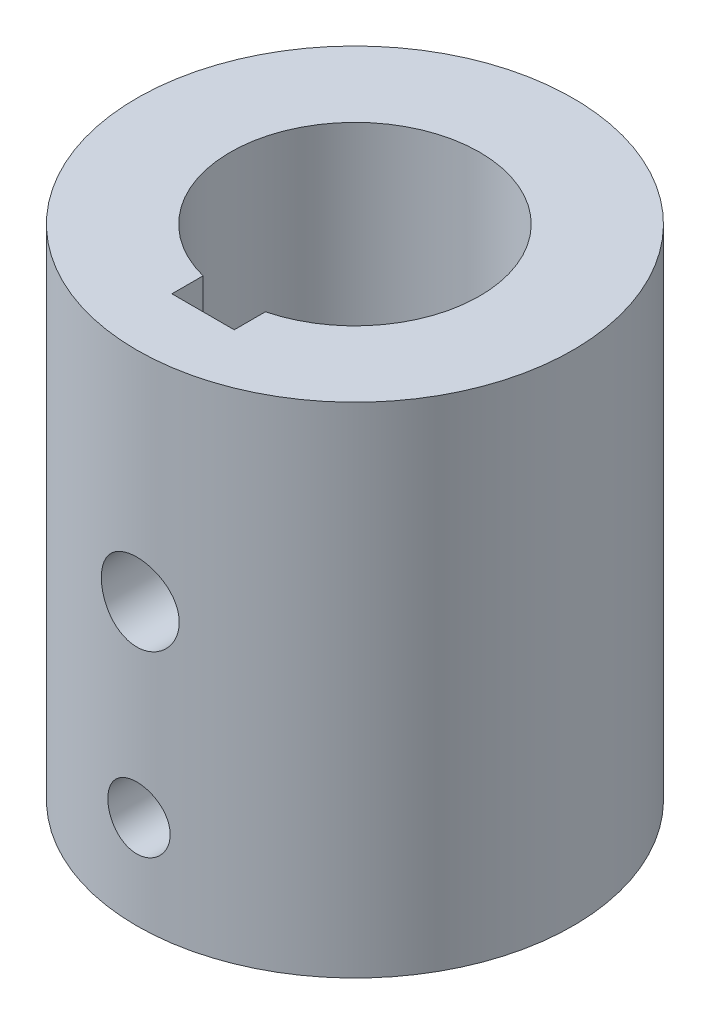
from build123d import *

# Parameters (mm, degrees)
SKETCH1_R                           = 22.225
SKETCH1_R_2                         = 12.7
BOSS_EXTRUDE1_DEPTH                 = 50.8
SKETCH2_R                           = 3.175
CUT_EXTRUDE1_DEPTH                  = 60.737268518
CUT_EXTRUDE1_DEPTH_BACK             = 60.737268518
F_5_16_0_3125_DIAMETER_HOLE1_REACH  = 59.326
F_5_16_0_3125_DIAMETER_HOLE1_BORE_R = 3.96875
CUT_EXTRUDE3_REACH                  = 61.737
SKETCH6_W                           = 6.35
SKETCH6_H                           = 3.175


with BuildPart() as part:
    # Sketch1 → Boss-Extrude1 (new body)
    with BuildSketch(Plane(origin=(0, 0, 0), x_dir=(1, 0, 0), z_dir=(0, 1, 0))):
        with Locations(Location((0, 0, 0), (0, 0, 270))):
            Circle(SKETCH1_R)
        with Locations(Location((0, 0, 0), (0, 0, 270))):
            Circle(SKETCH1_R_2, mode=Mode.SUBTRACT)
    extrude(amount=BOSS_EXTRUDE1_DEPTH)

    # Sketch2 → Cut-Extrude1 (cut, two sides)
    with BuildSketch(Plane.XY) as cut_extrude1_sk:
        with Locations((0, 9.525)):
            Circle(SKETCH2_R)
    extrude(amount=CUT_EXTRUDE1_DEPTH, mode=Mode.SUBTRACT)
    extrude(cut_extrude1_sk.sketch, amount=-CUT_EXTRUDE1_DEPTH_BACK, mode=Mode.SUBTRACT)

    # 5/16 (0.3125) Diameter Hole1 bore (on position points) → 5/16 (0.3125) Diameter Hole1 (cut, up to next)
    with BuildSketch(Plane(origin=(0, 28.575, 22.225), x_dir=(1, 0, 0), z_dir=(0, 0, 1)), mode=Mode.PRIVATE) as f_5_16_0_3125_diameter_hole1_sk1:
        Circle(F_5_16_0_3125_DIAMETER_HOLE1_BORE_R)
    f_5_16_0_3125_diameter_hole1_tool1 = extrude(f_5_16_0_3125_diameter_hole1_sk1.sketch, amount=-F_5_16_0_3125_DIAMETER_HOLE1_REACH, mode=Mode.PRIVATE) & part.part
    add(f_5_16_0_3125_diameter_hole1_tool1.solids().sort_by_distance((0, 28.575, 22.225))[0], mode=Mode.SUBTRACT)

    # Cut-Extrude3: up to this face of the body (flat: up to its plane)
    cut_extrude3_end = Plane(part.part.faces().sort_by_distance((0, 0, -21.596382072))[0])
    # Sketch6 → Cut-Extrude3 (cut, up to the picked face)
    with BuildSketch(Plane(origin=(0, 50.8, 0), x_dir=(1, 0, 0), z_dir=(0, 1, 0)), mode=Mode.PRIVATE) as cut_extrude3_sk1:
        with Locations((0, -13.884222124)):
            Rectangle(SKETCH6_W, SKETCH6_H)
    cut_extrude3_tool1 = split(extrude(cut_extrude3_sk1.sketch, amount=-CUT_EXTRUDE3_REACH, mode=Mode.PRIVATE), bisect_by=cut_extrude3_end, keep=Keep.BOTH, mode=Mode.PRIVATE)
    add(cut_extrude3_tool1.solids().sort_by(Axis((0, 50.8, 13.884222), (0, -1, 0)))[0], mode=Mode.SUBTRACT)


solid = part.part
